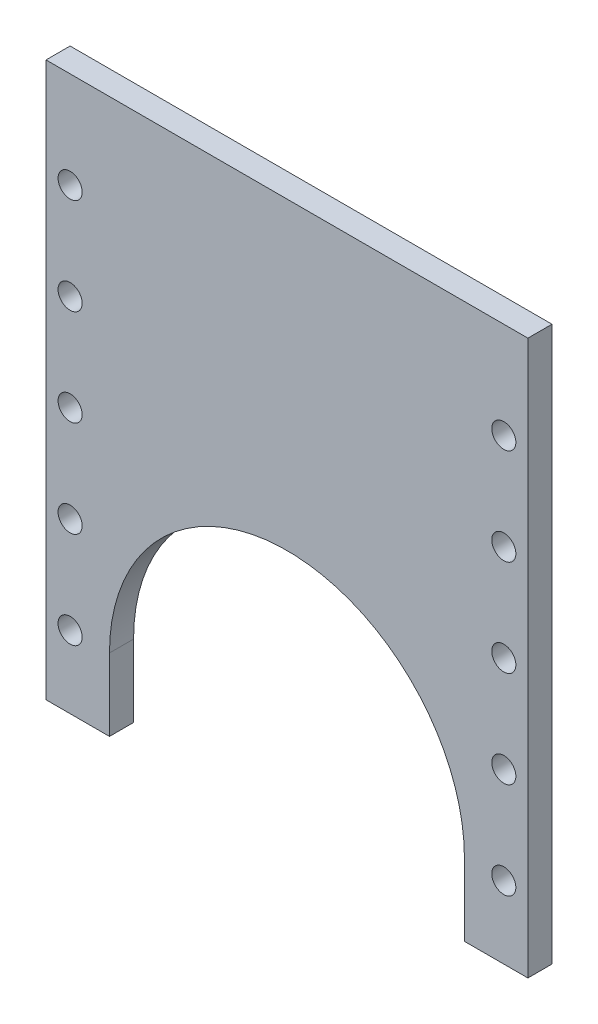
from build123d import *

# Parameters (mm, degrees)
SKETCH1_R           = 2.5
BOSS_EXTRUDE1_DEPTH = 5


with BuildPart() as part:
    # Sketch1 → Boss-Extrude1 (new body)
    with BuildSketch(Plane.XY):
        with BuildLine():
            Line((-50, -15), (-50, 100))
            Line((-50, 100), (50, 100))
            Line((50, 100), (50, -15))
            Line((50, -15), (36.83, -15))
            Line((36.83, -15), (36.83, 0))
            ThreePointArc((36.83, 0), (0, 36.83), (-36.83, 0))
            Line((-36.83, 0), (-36.83, -15))
            Line((-36.83, -15), (-50, -15))
        make_face()
        with Locations((-45, 0)):
            Circle(SKETCH1_R, mode=Mode.SUBTRACT)
        with Locations((45, 0)):
            Circle(SKETCH1_R, mode=Mode.SUBTRACT)
        with Locations((45, 20)):
            Circle(SKETCH1_R, mode=Mode.SUBTRACT)
        with Locations((45, 40)):
            Circle(SKETCH1_R, mode=Mode.SUBTRACT)
        with Locations((45, 60)):
            Circle(SKETCH1_R, mode=Mode.SUBTRACT)
        with Locations((45, 80)):
            Circle(SKETCH1_R, mode=Mode.SUBTRACT)
        with Locations((-45, 20)):
            Circle(SKETCH1_R, mode=Mode.SUBTRACT)
        with Locations((-45, 40)):
            Circle(SKETCH1_R, mode=Mode.SUBTRACT)
        with Locations((-45, 60)):
            Circle(SKETCH1_R, mode=Mode.SUBTRACT)
        with Locations((-45, 80)):
            Circle(SKETCH1_R, mode=Mode.SUBTRACT)
    extrude(amount=BOSS_EXTRUDE1_DEPTH)


solid = part.part
